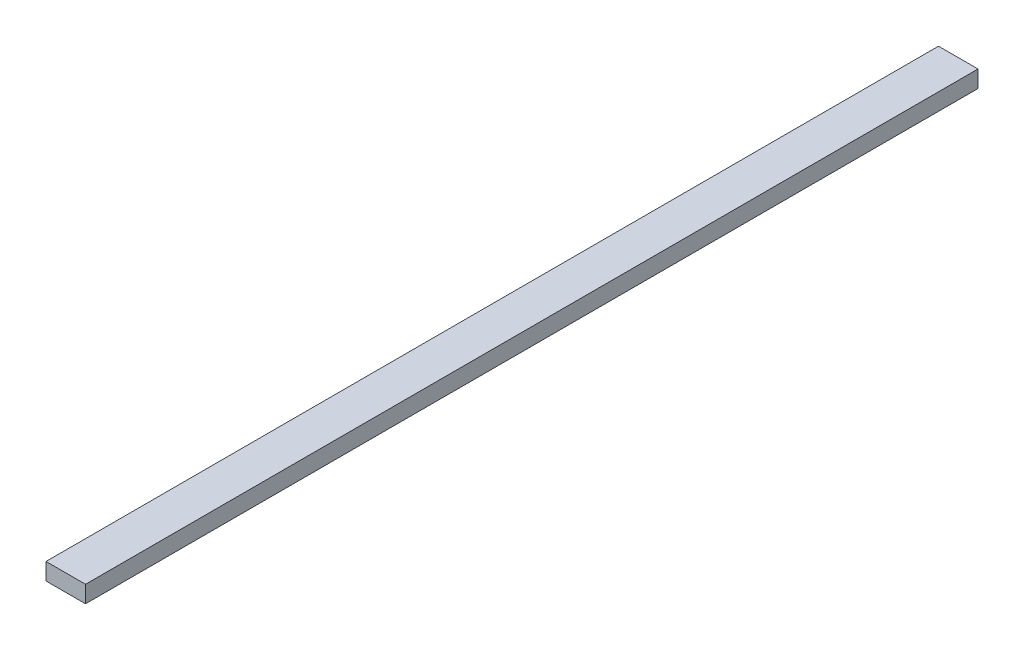
from build123d import *

# Parameters (mm, degrees)
SKETCH1_W           = 88.9
SKETCH1_H           = 38.1
BOSS_EXTRUDE1_DEPTH = 1003.968750123


with BuildPart() as part:
    # Sketch1 → Boss-Extrude1 (new body, symmetric)
    with BuildSketch(Plane.XY):
        with Locations((0, -19.05)):
            Rectangle(SKETCH1_W, SKETCH1_H)
    extrude(amount=BOSS_EXTRUDE1_DEPTH, both=True)


solid = part.part
